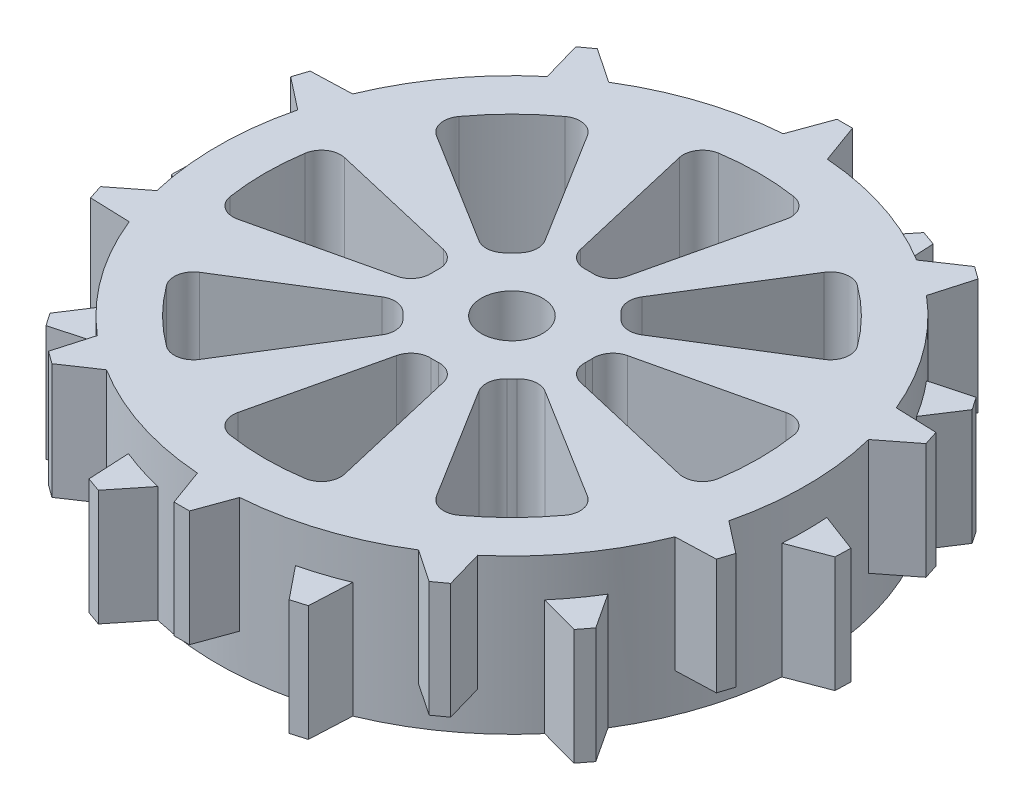
from build123d import *

# Parameters (mm, degrees)
SKETCH1_R           = 76.2
BOSS_EXTRUDE1_DEPTH = 40
BOSS_EXTRUDE2_DEPTH = 30
CIRPATTERN1_COUNT   = 10
BOSS_EXTRUDE3_DEPTH = 30
CIRPATTERN2_COUNT   = 10
SKETCH4_R           = 7.9375
CUT_EXTRUDE1_DEPTH  = 41
CUT_EXTRUDE2_DEPTH  = 41
CIRPATTERN3_COUNT   = 8
FILLET4_R           = 5
FILLET5_R           = 5


with BuildPart() as part:
    # Sketch1 → Boss-Extrude1 (new body)
    with BuildSketch(Plane(origin=(0, 0, 0), x_dir=(1, 0, 0), z_dir=(0, 1, 0))):
        Circle(SKETCH1_R)
    extrude(amount=BOSS_EXTRUDE1_DEPTH)

    # Sketch2 → Boss-Extrude2 (add)
    with BuildSketch(Plane(origin=(0, 40, 0), x_dir=(1, 0, 0), z_dir=(0, 1, 0))):
        with BuildLine():
            Line((0, 86.2), (0, 76.2))
            ThreePointArc((0, 76.2), (2.860964701, 76.146272929), (5.717894985, 75.98516748))
            Line((5.717894985, 75.98516748), (2, 86.2))
            Line((2, 86.2), (0, 86.2))
        make_face()
        with BuildLine():
            ThreePointArc((-5.717894985, 75.98516748), (-2.860964701, 76.146272929), (0, 76.2))
            Line((0, 76.2), (0, 86.2))
            Line((0, 86.2), (-2, 86.2))
            Line((-2, 86.2), (-5.717894985, 75.98516748))
        make_face()
    boss_extrude2 = extrude(amount=-BOSS_EXTRUDE2_DEPTH)

    # CirPattern1: Boss-Extrude2 ×10 about axis
    cirpattern1_axis = Axis((0, 0, -0.338660651), (0, 1, 0))
    for i in range(1, CIRPATTERN1_COUNT):
        add(boss_extrude2.rotate(cirpattern1_axis, i * 360 / CIRPATTERN1_COUNT))

    # Sketch3 → Boss-Extrude3 (add)
    with BuildSketch(Plane.XZ):
        with BuildLine():
            Line((24.811616962, 82.515457643), (17.980532935, 74.048230468))
            ThreePointArc((17.980532935, 74.048230468), (20.820375524, 73.300422666), (23.629294983, 72.44374658))
            Line((23.629294983, 72.44374658), (26.73025233, 81.950799937))
            Line((26.73025233, 81.950799937), (24.811616962, 82.515457643))
        make_face()
        with BuildLine():
            Line((26.73025233, 81.950799937), (23.629294983, 72.44374658))
            ThreePointArc((23.629294983, 72.44374658), (26.423605423, 71.471904105), (29.178084826, 70.392324624))
            Line((29.178084826, 70.392324624), (28.648887698, 81.386142232))
            Line((28.648887698, 81.386142232), (26.73025233, 81.950799937))
        make_face()
    boss_extrude3 = extrude(amount=-BOSS_EXTRUDE3_DEPTH)

    # CirPattern2: Boss-Extrude3 ×10 about axis
    cirpattern2_axis = Axis((0.107387074, 0, 0.328898849), (0, 1, 0))
    for i in range(1, CIRPATTERN2_COUNT):
        add(boss_extrude3.rotate(cirpattern2_axis, i * 360 / CIRPATTERN2_COUNT))

    # Sketch4 → Cut-Extrude1 (cut, through all)
    with BuildSketch(Plane(origin=(0, 40, 0), x_dir=(1, 0, 0), z_dir=(0, 1, 0))):
        Circle(SKETCH4_R)
    extrude(amount=-CUT_EXTRUDE1_DEPTH, mode=Mode.SUBTRACT)

    # Sketch5 → Cut-Extrude2 (cut, through all)
    with BuildSketch(Plane(origin=(0, 40, 0), x_dir=(1, 0, 0), z_dir=(0, 1, 0))):
        with BuildLine():
            ThreePointArc((15, 62.217360921), (0, 64), (-15, 62.217360921))
            Line((-15, 62.217360921), (-5, 19.364916731))
            ThreePointArc((-5, 19.364916731), (0, 20), (5, 19.364916731))
            Line((5, 19.364916731), (15, 62.217360921))
        make_face()
    cut_extrude2 = extrude(amount=-CUT_EXTRUDE2_DEPTH, mode=Mode.SUBTRACT)

    # CirPattern3: Cut-Extrude2 ×8 about axis
    cirpattern3_axis = Axis((0, 0, 0), (0, 1, 0))
    for i in range(1, CIRPATTERN3_COUNT):
        add(cut_extrude2.rotate(cirpattern3_axis, i * 360 / CIRPATTERN3_COUNT), mode=Mode.SUBTRACT)

    # Fillet4
    fillet4_edges = [part.edges().sort_by_distance(p)[0] for p in [
        (5, 20, -19.364916731),
        (-5, 20, -19.364916731),
        (15, 20, -62.217360921),
        (-5, 20, 19.364916731),
        (5, 20, 19.364916731),
        (-15, 20, 62.217360921),
        (10.157530032, 20, 17.228597844),
        (17.228597844, 20, 10.157530032),
        (33.387716097, 20, 54.600919533),
        (-19.364916731, 20, -5),
        (-19.364916731, 20, 5),
        (-62.217360921, 20, -15),
        (-17.228597844, 20, 10.157530032),
        (-10.157530032, 20, 17.228597844),
        (-54.600919533, 20, 33.387716097),
        (17.228597844, 20, -10.157530032),
        (10.157530032, 20, -17.228597844),
        (54.600919533, 20, -33.387716097),
        (19.364916731, 20, 5),
        (19.364916731, 20, -5),
        (62.217360921, 20, 15),
        (-10.157530032, 20, -17.228597844),
        (-17.228597844, 20, -10.157530032),
        (-33.387716097, 20, -54.600919533),
    ]]
    fillet(fillet4_edges, radius=FILLET4_R)

    # Fillet5
    fillet5_edges = [part.edges().sort_by_distance(p)[0] for p in [
        (-15, 20, -62.217360921),
        (15, 20, 62.217360921),
        (54.600919533, 20, 33.387716097),
        (-62.217360921, 20, 15),
        (-33.387716097, 20, 54.600919533),
        (33.387716097, 20, -54.600919533),
        (62.217360921, 20, -15),
        (-54.600919533, 20, -33.387716097),
    ]]
    fillet(fillet5_edges, radius=FILLET5_R)


solid = part.part
